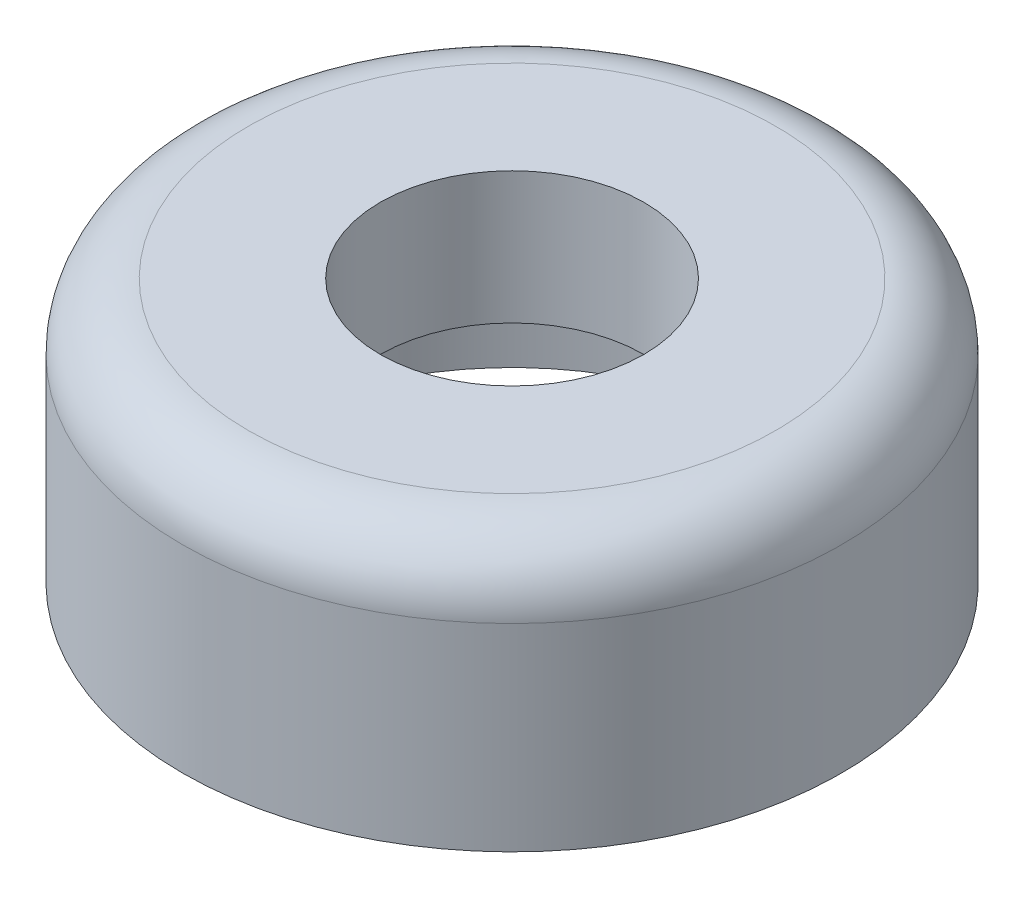
from build123d import *


with BuildPart() as part:
    # Sketch1 → Base-Revolve (revolve)
    with BuildSketch(Plane.XY, mode=Mode.PRIVATE) as base_revolve_sk:
        with BuildLine():
            Line((50.8, 101.6), (50.8, 50.8))
            Line((50.8, 50.8), (76.2, 50.8))
            Line((76.2, 50.8), (101.6, 25.4))
            Line((101.6, 25.4), (101.6, 0))
            Line((101.6, 0), (127, 0))
            Line((127, 0), (127, 76.2))
            ThreePointArc((127, 76.2), (119.560512242, 94.160512242), (101.6, 101.6))
            Line((101.6, 101.6), (50.8, 101.6))
        make_face()
    revolve(base_revolve_sk.sketch.rotate(Axis((0, 127, 0), (0, -1, 0)), 90), axis=Axis((0, 127, 0), (0, -1, 0)))  # turned: the seam where the file's is


solid = part.part
